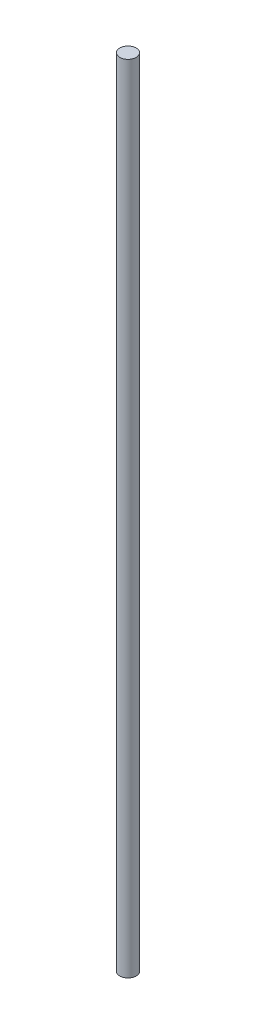
from build123d import *

# Parameters (mm, degrees)
SKETCH1_R           = 3
BOSS_EXTRUDE1_DEPTH = 292


with BuildPart() as part:
    # Sketch1 → Boss-Extrude1 (new body)
    with BuildSketch(Plane(origin=(0, 0, 0), x_dir=(1, 0, 0), z_dir=(0, 1, 0))):
        Circle(SKETCH1_R)
    extrude(amount=BOSS_EXTRUDE1_DEPTH)


solid = part.part
